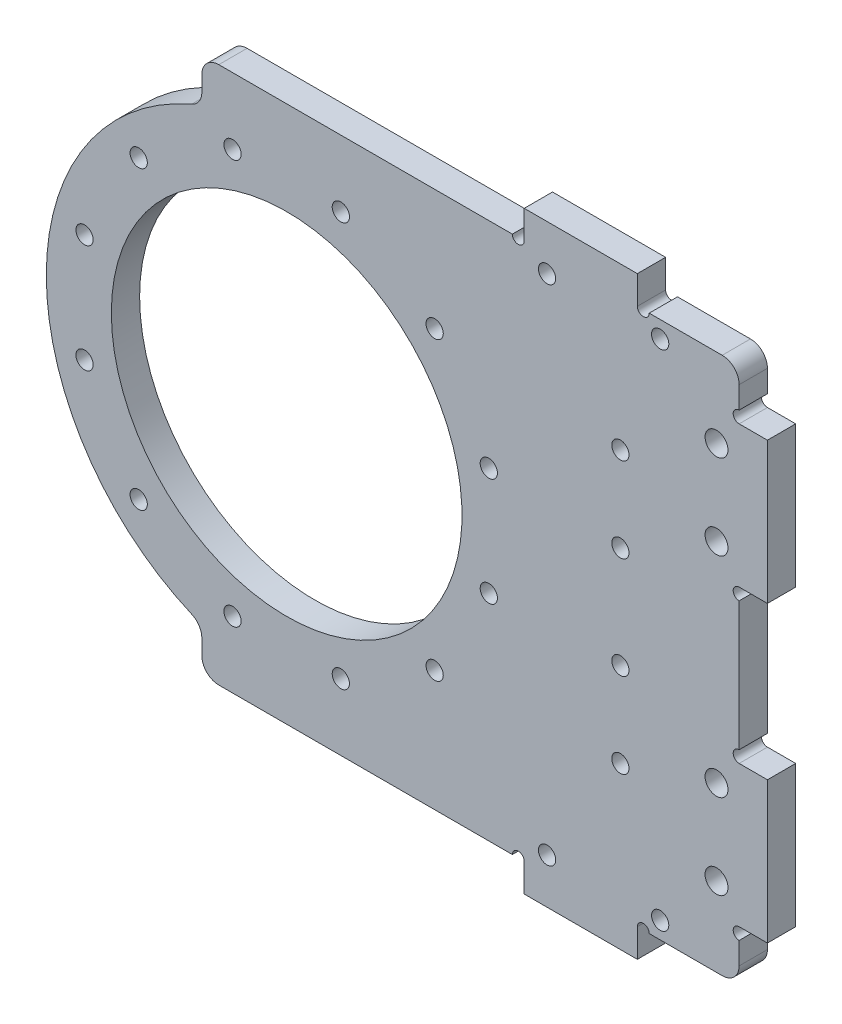
from build123d import *

# Parameters (mm, degrees)
EXTRUDE_1_DEPTH          = 2.5
FILLET_2_R               = 10
FILLET_3_R               = 3
SKETCH_2_R               = 31
CUT_EXTRUDE_1_DEPTH      = 1
CUT_EXTRUDE_1_DEPTH_BACK = 6
SKETCH_3_R               = 1.525
CUT_EXTRUDE_2_DEPTH      = 1
CUT_EXTRUDE_2_DEPTH_BACK = 6
SKETCH_4_R               = 2.025
CUT_EXTRUDE_3_DEPTH      = 6
EXTRUDE_2_DEPTH          = 5
FILLET_4_R               = 3
SKETCH_8_R               = 1.525
CUT_EXTRUDE_6_DEPTH      = 10
SKETCH_9_W               = 20
SKETCH_9_H               = 5
EXTRUDE_3_DEPTH          = 5
CUT_EXTRUDE_7_DEPTH      = 14
SKETCH_11_W              = 5
SKETCH_11_H              = 25
EXTRUDE_4_DEPTH          = 5
CUT_EXTRUDE_8_DEPTH      = 5
SKETCH_13_R              = 1.525
CUT_EXTRUDE_9_DEPTH      = 6


with BuildPart() as part:
    # 草图1 → 凸台-拉伸1 (new body, symmetric)
    with BuildSketch(Plane.XY):
        with BuildLine():
            Line((80, 47.5), (80, -47.5))
            Line((80, -47.5), (15, -47.5))
            Line((15, -47.5), (-10.218604944, -41.253243666))
            ThreePointArc((-10.218604944, -41.253243666), (-42.5, 0), (-10.218604944, 41.253243666))
            Line((-10.218604944, 41.253243666), (15, 47.5))
            Line((15, 47.5), (80, 47.5))
        make_face()
    extrude(amount=EXTRUDE_1_DEPTH, both=True)

    # 圆角2
    fillet_2_edges = [part.edges().sort_by_distance(p)[0] for p in [
        (15, -47.5, 0),
        (15, 47.5, 0),
    ]]
    fillet(fillet_2_edges, radius=FILLET_2_R)

    # 圆角3
    fillet_3_edges = [part.edges().sort_by_distance(p)[0] for p in [
        (80, 47.5, 0),
        (80, -47.5, 0),
    ]]
    fillet(fillet_3_edges, radius=FILLET_3_R)

    # 草图2 → 切除-拉伸1 (cut, two sides)
    with BuildSketch(Plane(origin=(0, 0, -2.5), x_dir=(-1, 0, 0), z_dir=(0, 0, -1))) as cut_extrude_1_sk:
        Circle(SKETCH_2_R)
    extrude(amount=CUT_EXTRUDE_1_DEPTH, mode=Mode.SUBTRACT)
    extrude(cut_extrude_1_sk.sketch, amount=-CUT_EXTRUDE_1_DEPTH_BACK, mode=Mode.SUBTRACT)

    # 草图3 → 切除-拉伸2 (cut, two sides)
    with BuildSketch(Plane.XY.offset(2.5)) as cut_extrude_2_sk:
        with Locations((9.576304669, 35.739255573)):
            Circle(SKETCH_3_R)
        with Locations((26.162950904, 26.162950904)):
            Circle(SKETCH_3_R)
        with Locations((35.739255573, 9.576304669)):
            Circle(SKETCH_3_R)
        with Locations((35.739255573, -9.576304669)):
            Circle(SKETCH_3_R)
        with Locations((26.162950904, -26.162950904)):
            Circle(SKETCH_3_R)
        with Locations((9.576304669, -35.739255573)):
            Circle(SKETCH_3_R)
        with Locations((-9.576304669, -35.739255573)):
            Circle(SKETCH_3_R)
        with Locations((-26.162950904, -26.162950904)):
            Circle(SKETCH_3_R)
        with Locations((-35.739255573, -9.576304669)):
            Circle(SKETCH_3_R)
        with Locations((-35.739255573, 9.576304669)):
            Circle(SKETCH_3_R)
        with Locations((-26.162950904, 26.162950904)):
            Circle(SKETCH_3_R)
        with Locations((-9.576304669, 35.739255573)):
            Circle(SKETCH_3_R)
    extrude(amount=CUT_EXTRUDE_2_DEPTH, mode=Mode.SUBTRACT)
    extrude(cut_extrude_2_sk.sketch, amount=-CUT_EXTRUDE_2_DEPTH_BACK, mode=Mode.SUBTRACT)

    # 草图4 → 切除-拉伸3 (cut, through all)
    with BuildSketch(Plane.XY.offset(2.5)):
        with Locations((76, -33.5)):
            Circle(SKETCH_4_R)
        with Locations((76, -18.5)):
            Circle(SKETCH_4_R)
        with Locations((76, 18.5)):
            Circle(SKETCH_4_R)
        with Locations((76, 33.5)):
            Circle(SKETCH_4_R)
    extrude(amount=-CUT_EXTRUDE_3_DEPTH, mode=Mode.SUBTRACT)

    # 草图6 → 凸台-拉伸2 (add)
    with BuildSketch(Plane.XY.offset(2.5)):
        with BuildLine():
            Line((-15, 44.5), (-15, 39.764934301))
            Line((-15, 39.764934301), (16.220084679, 47.5))
            Line((16.220084679, 47.5), (-12, 47.5))
            ThreePointArc((-12, 47.5), (-14.121320344, 46.621320344), (-15, 44.5))
        make_face()
    extrude_2 = extrude(amount=-EXTRUDE_2_DEPTH)

    # 镜向1: 凸台-拉伸2 across plane
    add(extrude_2.mirror(Plane.ZX))

    # 圆角4
    fillet_4_edges = [part.edges().sort_by_distance(p)[0] for p in [
        (-15, 39.764934301, 0),
        (-15, -39.764934301, 0),
    ]]
    fillet(fillet_4_edges, radius=FILLET_4_R)

    # 草图8 → 切除-拉伸6 (cut)
    with BuildSketch(Plane.XY.offset(2.5)):
        with Locations((66.03743584, 44.5)):
            Circle(SKETCH_8_R)
        with Locations((46.03743584, 44.5)):
            Circle(SKETCH_8_R)
    cut_extrude_6 = extrude(amount=-CUT_EXTRUDE_6_DEPTH, mode=Mode.SUBTRACT)

    # 草图9 → 凸台-拉伸3 (add)
    with BuildSketch(Plane(origin=(0, 47.5, 0), x_dir=(1, 0, 0), z_dir=(0, 1, 0))):
        with Locations((52, 0)):
            Rectangle(SKETCH_9_W, SKETCH_9_H)
    extrude_3 = extrude(amount=EXTRUDE_3_DEPTH)

    # 草图10 → 切除-拉伸7 (cut)
    with BuildSketch(Plane.XY.offset(2.5)):
        with BuildLine():
            Line((39.9, 47.5), (42, 47.5))
            ThreePointArc((42, 47.5), (40.95, 46.45), (39.9, 47.5))
        make_face()
        with BuildLine():
            Line((62, 47.5), (64.1, 47.5))
            ThreePointArc((64.1, 47.5), (63.05, 46.45), (62, 47.5))
        make_face()
    cut_extrude_7 = extrude(amount=-CUT_EXTRUDE_7_DEPTH, mode=Mode.SUBTRACT)

    # 镜向3: 切除-拉伸6, 凸台-拉伸3 across plane
    add(cut_extrude_6.mirror(Plane.ZX), mode=Mode.SUBTRACT)
    add(extrude_3.mirror(Plane.ZX))

    # 草图11 → 凸台-拉伸4 (add)
    with BuildSketch(Plane(origin=(80, 0, 0), x_dir=(0, 0, -1), z_dir=(1, 0, 0))):
        with Locations((0, 26)):
            Rectangle(SKETCH_11_W, SKETCH_11_H)
    extrude_4 = extrude(amount=EXTRUDE_4_DEPTH)

    # 草图12 → 切除-拉伸8 (cut)
    with BuildSketch(Plane.XY.offset(2.5)):
        with BuildLine():
            Line((80, 11.4), (80, 13.5))
            ThreePointArc((80, 13.5), (78.95, 12.45), (80, 11.4))
        make_face()
        with BuildLine():
            Line((80, 40.6), (80, 38.5))
            ThreePointArc((80, 38.5), (78.95, 39.55), (80, 40.6))
        make_face()
    cut_extrude_8 = extrude(amount=-CUT_EXTRUDE_8_DEPTH, mode=Mode.SUBTRACT)

    # 镜向4: 凸台-拉伸4, 切除-拉伸8 across plane
    add(extrude_4.mirror(Plane.ZX))
    add(cut_extrude_8.mirror(Plane.ZX), mode=Mode.SUBTRACT)

    # 草图13 → 切除-拉伸9 (cut, through all)
    with BuildSketch(Plane.XY.offset(2.5)):
        with Locations((59, 9)):
            Circle(SKETCH_13_R)
        with Locations((59, 24)):
            Circle(SKETCH_13_R)
    cut_extrude_9 = extrude(amount=-CUT_EXTRUDE_9_DEPTH, mode=Mode.SUBTRACT)

    # 镜向5: 切除-拉伸9 across plane
    add(cut_extrude_9.mirror(Plane.ZX), mode=Mode.SUBTRACT)

    # 镜向6: 凸台-拉伸3, 切除-拉伸7 across plane
    add(extrude_3.mirror(Plane.ZX))
    add(cut_extrude_7.mirror(Plane.ZX), mode=Mode.SUBTRACT)


solid = part.part
